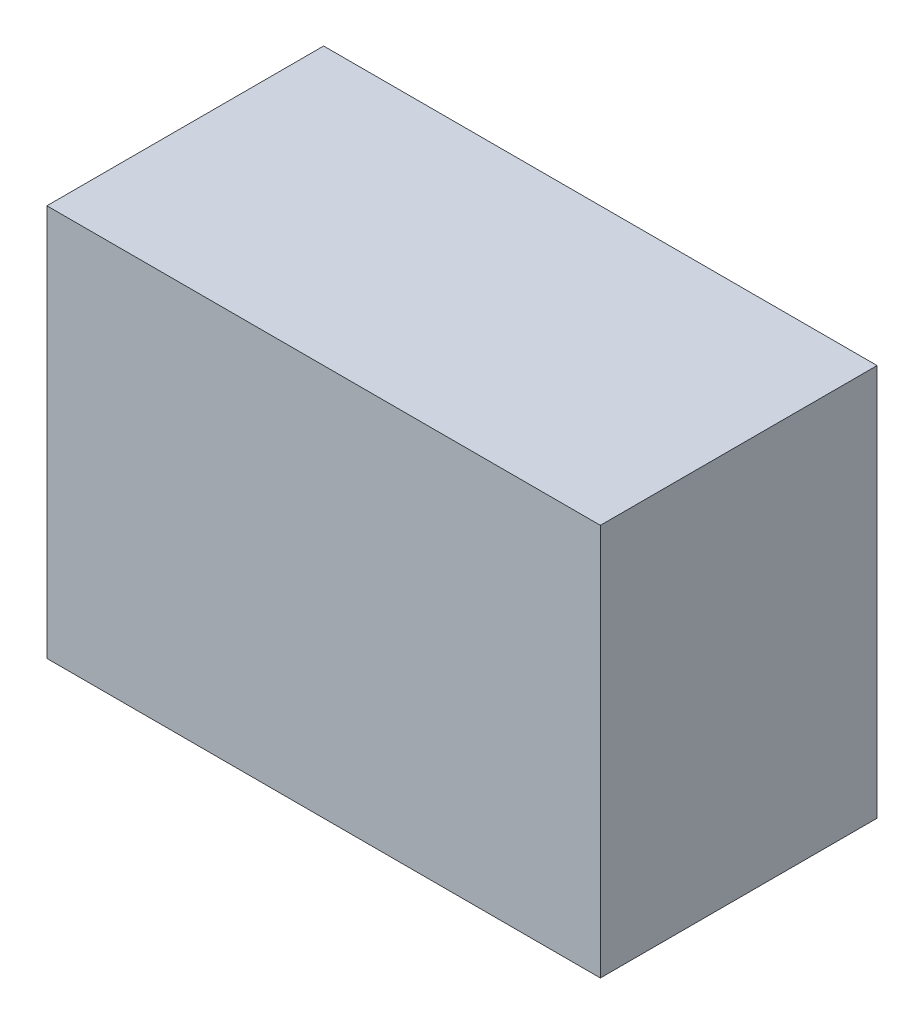
from build123d import *

# Parameters (mm, degrees)
SKETCH1_W           = 48
SKETCH1_H           = 24
BOSS_EXTRUDE1_DEPTH = 34
SHELL1_T            = -2
CUT_EXTRUDE1_DEPTH  = 2
SKETCH3_W           = 6.5
SKETCH3_H           = 17.142463893
BOSS_EXTRUDE2_DEPTH = 32
SKETCH4_R           = 1.75
CUT_EXTRUDE2_DEPTH  = 10


with BuildPart() as part:
    # Sketch1 → Boss-Extrude1 (new body)
    with BuildSketch(Plane(origin=(0, 0, 0), x_dir=(1, 0, 0), z_dir=(0, 1, 0))):
        with Locations((0, -2.545302013)):
            Rectangle(SKETCH1_W, SKETCH1_H)
    extrude(amount=BOSS_EXTRUDE1_DEPTH)

    # Shell1
    shell1_openings = [part.faces().sort_by_distance(p)[0] for p in [
        (0, 0, 2.545302013),
    ]]
    offset(amount=SHELL1_T, openings=shell1_openings, kind=Kind.INTERSECTION)

    # Sketch2 → Cut-Extrude1 (cut)
    with BuildSketch(Plane(origin=(0, 0, -9.454697987), x_dir=(-1, 0, 0), z_dir=(0, 0, -1))):
        with BuildLine():
            Line((-6.502577746, 0), (6.502577746, 0))
            Line((6.502577746, 0), (6.502577746, 25))
            ThreePointArc((6.502577746, 25), (0, 31.502577746), (-6.502577746, 25))
            Line((-6.502577746, 25), (-6.502577746, 0))
        make_face()
    extrude(amount=-CUT_EXTRUDE1_DEPTH, mode=Mode.SUBTRACT)

    # Sketch3 → Boss-Extrude2 (add)
    with BuildSketch(Plane.XZ.offset(-32)):
        with Locations((18.75, 3.974070066)):
            Rectangle(SKETCH3_W, SKETCH3_H)
        with Locations((-18.75, 3.974070066)):
            Rectangle(SKETCH3_W, SKETCH3_H)
    extrude(amount=BOSS_EXTRUDE2_DEPTH)

    # Sketch4 → Cut-Extrude2 (cut)
    with BuildSketch(Plane.XZ):
        with Locations((20, 5.545302013)):
            Circle(SKETCH4_R)
        with Locations((-20, 5.545302013)):
            Circle(SKETCH4_R)
    extrude(amount=-CUT_EXTRUDE2_DEPTH, mode=Mode.SUBTRACT)


solid = part.part
